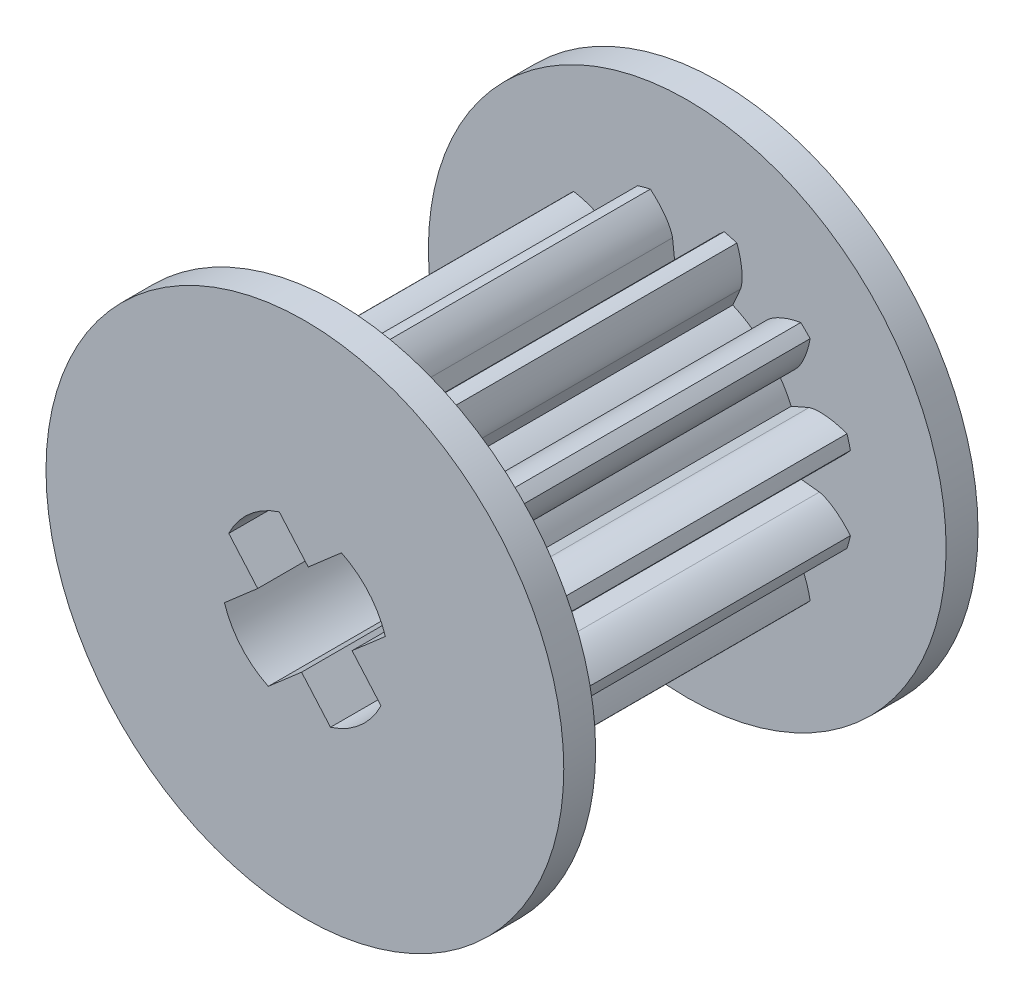
from build123d import *

# Parameters (mm, degrees)
SKETCH1_R               = 5.25
BOSS_EXTRUDE1_DEPTH     = 11
CUT_EXTRUDE3_DEPTH      = 14.27120944
CIRPATTERN1_COUNT       = 12
SKETCH6_R               = 8.125
BOSS_EXTRUDE2_DEPTH     = 1
CUT_EXTRUDE4_DEPTH      = 17.614188312
CUT_EXTRUDE4_DEPTH_BACK = 17.614188312


with BuildPart() as part:
    # Sketch1 → Boss-Extrude1 (new body)
    with BuildSketch(Plane.XY):
        Circle(SKETCH1_R)
    extrude(amount=BOSS_EXTRUDE1_DEPTH)

    # Sketch3 → Cut-Extrude3 (cut, through all)
    with BuildSketch(Plane.XY):
        with BuildLine():
            add(Edge.make_bspline(
                [(0.461546791, 4.146720396), (0.463953922, 4.163714882), (0.472985914, 4.201315534), (0.494149183, 4.266634462), (0.528558847, 4.349970943), (0.562413319, 4.416839281), (0.584280793, 4.45603904), (0.587367865, 4.461501876)],
                knots=[0, 0, 0, 0, 0.040008387, 0.090017613, 0.160030412, 0.250046806, 0.264674884, 0.264674884, 0.264674884, 0.264674884], degree=3))
            add(Edge.make_bspline(
                [(0.587367865, 4.461501876), (0.634900369, 4.545614692), (0.726044104, 4.679105945), (0.914750766, 4.902091874), (1.057206539, 5.036685302), (1.15776547, 5.120749859)],
                knots=[0.264674884, 0.264674884, 0.264674884, 0.264674884, 0.489907489, 0.63993471, 0.945583804, 0.945583804, 0.945583804, 0.945583804], degree=3))
            ThreePointArc((1.15776547, 5.120749859), (0, 5.25), (-1.15776547, 5.120749859))
            add(Edge.make_bspline(
                [(-0.587367865, 4.461501876), (-0.634900369, 4.545614692), (-0.726044104, 4.679105945), (-0.914750766, 4.902091874), (-1.057206539, 5.036685302), (-1.15776547, 5.120749859)],
                knots=[0.264674884, 0.264674884, 0.264674884, 0.264674884, 0.489907489, 0.63993471, 0.945583804, 0.945583804, 0.945583804, 0.945583804], degree=3))
            add(Edge.make_bspline(
                [(-0.461546791, 4.146720396), (-0.463953922, 4.163714882), (-0.472985914, 4.201315534), (-0.494149183, 4.266634462), (-0.528558847, 4.349970943), (-0.562413319, 4.416839281), (-0.584280793, 4.45603904), (-0.587367865, 4.461501876)],
                knots=[0, 0, 0, 0, 0.040008387, 0.090017613, 0.160030412, 0.250046806, 0.264674884, 0.264674884, 0.264674884, 0.264674884], degree=3))
            Line((-0.461546791, 4.146720396), (-0.394087114, 3.540635762))
            ThreePointArc((-0.394087114, 3.540635762), (0, 3.5625), (0.394087114, 3.540635762))
            Line((0.394087114, 3.540635762), (0.461546791, 4.146720396))
        make_face()
    cut_extrude3 = extrude(amount=CUT_EXTRUDE3_DEPTH, mode=Mode.SUBTRACT)

    # CirPattern1: Cut-Extrude3 ×12 about axis
    cirpattern1_axis = Axis((0, 0, 71.213492813), (0, 0, -1))
    for i in range(1, CIRPATTERN1_COUNT):
        add(cut_extrude3.rotate(cirpattern1_axis, i * 360 / CIRPATTERN1_COUNT), mode=Mode.SUBTRACT)

    # Sketch6 → Boss-Extrude2 (add)
    with BuildSketch(Plane.XY.offset(11)):
        Circle(SKETCH6_R)
    boss_extrude2 = extrude(amount=BOSS_EXTRUDE2_DEPTH)

    # Mirror1: Boss-Extrude2 across plane
    add(boss_extrude2.mirror(Plane.XY.offset(5.5)))

    # Sketch5 → Cut-Extrude4 (cut, two sides: drawn at the far end of the back side and taken through both)
    with BuildSketch(Plane.XY.offset(-CUT_EXTRUDE4_DEPTH_BACK)):
        with BuildLine():
            Line((1.147891735, 2.388481644), (0.103872104, 1.481286801))
            Line((0.103872104, 1.481286801), (-0.80332274, 2.525306432))
            ThreePointArc((-0.80332274, 2.525306432), (-1.738166165, 2.00031957), (-2.388481644, 1.147891735))
            Line((-2.388481644, 1.147891735), (-1.481286801, 0.103872104))
            Line((-1.481286801, 0.103872104), (-2.525306432, -0.80332274))
            ThreePointArc((-2.525306432, -0.80332274), (-2.00031957, -1.738166165), (-1.147891735, -2.388481644))
            Line((-1.147891735, -2.388481644), (-0.103872104, -1.481286801))
            Line((-0.103872104, -1.481286801), (0.80332274, -2.525306432))
            ThreePointArc((0.80332274, -2.525306432), (1.738166165, -2.00031957), (2.388481644, -1.147891735))
            Line((2.388481644, -1.147891735), (1.481286801, -0.103872104))
            Line((1.481286801, -0.103872104), (2.525306432, 0.80332274))
            ThreePointArc((2.525306432, 0.80332274), (2.00031957, 1.738166165), (1.147891735, 2.388481644))
        make_face()
    extrude(amount=CUT_EXTRUDE4_DEPTH + CUT_EXTRUDE4_DEPTH_BACK, mode=Mode.SUBTRACT)


solid = part.part
